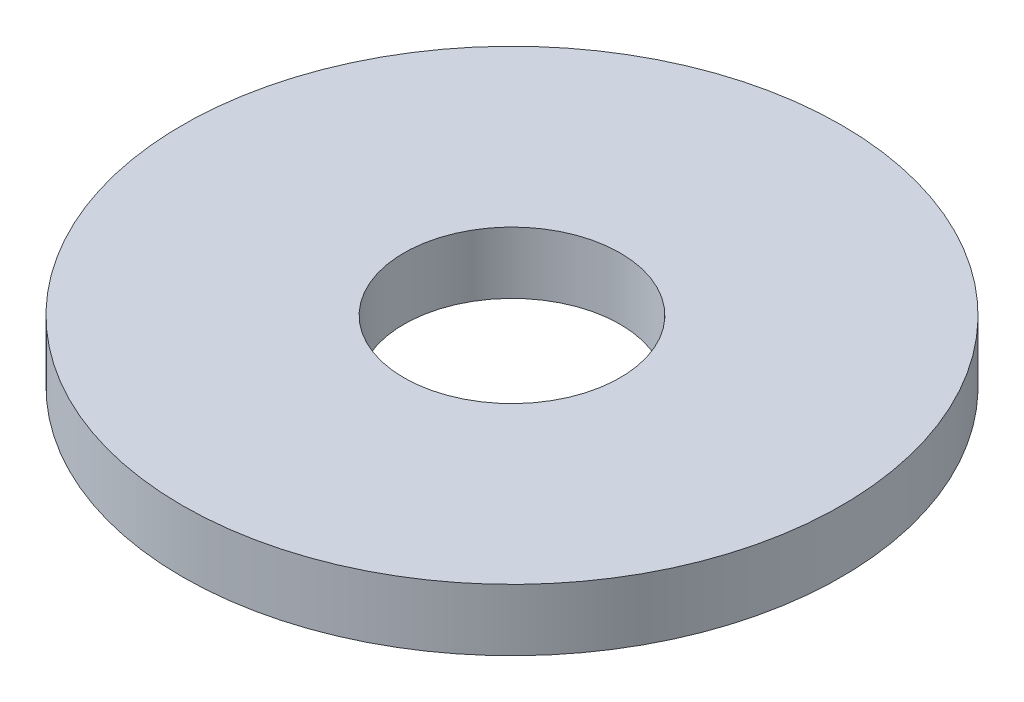
from build123d import *

# Parameters (mm, degrees)
SKETCH1_R           = 50.8
SKETCH1_R_2         = 16.66875
BOSS_EXTRUDE1_DEPTH = 9.525


with BuildPart() as part:
    # Sketch1 → Boss-Extrude1 (new body)
    with BuildSketch(Plane(origin=(0, 0, 0), x_dir=(1, 0, 0), z_dir=(0, 1, 0))):
        Circle(SKETCH1_R)
        Circle(SKETCH1_R_2, mode=Mode.SUBTRACT)
    extrude(amount=BOSS_EXTRUDE1_DEPTH)


solid = part.part
